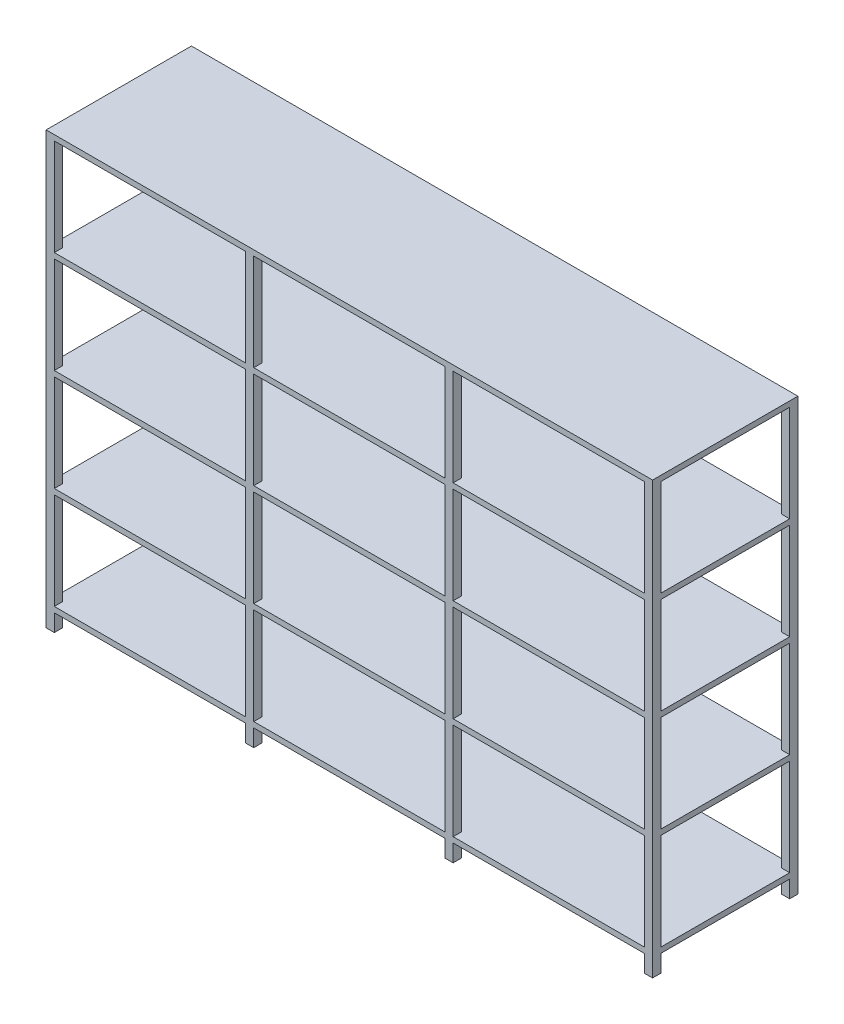
from build123d import *

# Parameters (mm, degrees)
CROQUIS1_W                = 38.1
CROQUIS1_H                = 38.1
SALIENTE_EXTRUIR1_DEPTH   = 80
SALIENTE_EXTRUIR1_2_DEPTH = 80
SALIENTE_EXTRUIR1_3_DEPTH = 80
SALIENTE_EXTRUIR1_4_DEPTH = 80
SALIENTE_EXTRUIR1_5_DEPTH = 80
SALIENTE_EXTRUIR1_6_DEPTH = 80
SALIENTE_EXTRUIR1_7_DEPTH = 80
SALIENTE_EXTRUIR1_8_DEPTH = 80
CROQUIS2_W                = 2822.4
CROQUIS2_H                = 676.2
SALIENTE_EXTRUIR2_DEPTH   = 25.4
CROQUIS3_W                = 38.1
CROQUIS3_H                = 38.1
SALIENTE_EXTRUIR3_DEPTH   = 450
CROQUIS4_W                = 2822.4
CROQUIS4_H                = 676.2
SALIENTE_EXTRUIR4_DEPTH   = 25.4
CROQUIS5_W                = 38.1
CROQUIS5_H                = 38.1
SALIENTE_EXTRUIR5_DEPTH   = 450
CROQUIS6_W                = 2822.4
CROQUIS6_H                = 676.2
SALIENTE_EXTRUIR6_DEPTH   = 25.4
CROQUIS7_W                = 38.1
CROQUIS7_H                = 38.1
SALIENTE_EXTRUIR7_DEPTH   = 450
CROQUIS8_W                = 2822.4
CROQUIS8_H                = 676.2
SALIENTE_EXTRUIR8_DEPTH   = 25.4
CROQUIS9_W                = 38.1
CROQUIS9_H                = 38.1
SALIENTE_EXTRUIR9_DEPTH   = 450
CROQUIS10_W               = 2822.4
CROQUIS10_H               = 676.2
SALIENTE_EXTRUIR10_DEPTH  = 25.4


with BuildPart() as part:
    # Croquis1 → Saliente-Extruir1 (new body)
    with BuildSketch(Plane(origin=(0, 0, 0), x_dir=(1, 0, 0), z_dir=(0, 1, 0))):
        with Locations((19.05, -19.05)):
            Rectangle(CROQUIS1_W, CROQUIS1_H)
    extrude(amount=SALIENTE_EXTRUIR1_DEPTH)



with BuildPart() as body_2:
    # Croquis1 → Saliente-Extruir1 2 (new body)
    with BuildSketch(Plane(origin=(0, 0, 0), x_dir=(1, 0, 0), z_dir=(0, 1, 0))):
        with Locations((947.15, -19.05)):
            Rectangle(CROQUIS1_W, CROQUIS1_H)
    extrude(amount=SALIENTE_EXTRUIR1_2_DEPTH)


with BuildPart() as body_3:
    # Croquis1 → Saliente-Extruir1 3 (new body)
    with BuildSketch(Plane(origin=(0, 0, 0), x_dir=(1, 0, 0), z_dir=(0, 1, 0))):
        with Locations((1875.25, -19.05)):
            Rectangle(CROQUIS1_W, CROQUIS1_H)
    extrude(amount=SALIENTE_EXTRUIR1_3_DEPTH)


with BuildPart() as body_4:
    # Croquis1 → Saliente-Extruir1 4 (new body)
    with BuildSketch(Plane(origin=(0, 0, 0), x_dir=(1, 0, 0), z_dir=(0, 1, 0))):
        with Locations((2803.35, -19.05)):
            Rectangle(CROQUIS1_W, CROQUIS1_H)
    extrude(amount=SALIENTE_EXTRUIR1_4_DEPTH)


with BuildPart() as body_5:
    # Croquis1 → Saliente-Extruir1 5 (new body)
    with BuildSketch(Plane(origin=(0, 0, 0), x_dir=(1, 0, 0), z_dir=(0, 1, 0))):
        with Locations((2803.35, -657.15)):
            Rectangle(CROQUIS1_W, CROQUIS1_H)
    extrude(amount=SALIENTE_EXTRUIR1_5_DEPTH)


with BuildPart() as body_6:
    # Croquis1 → Saliente-Extruir1 6 (new body)
    with BuildSketch(Plane(origin=(0, 0, 0), x_dir=(1, 0, 0), z_dir=(0, 1, 0))):
        with Locations((1875.25, -657.15)):
            Rectangle(CROQUIS1_W, CROQUIS1_H)
    extrude(amount=SALIENTE_EXTRUIR1_6_DEPTH)


with BuildPart() as body_7:
    # Croquis1 → Saliente-Extruir1 7 (new body)
    with BuildSketch(Plane(origin=(0, 0, 0), x_dir=(1, 0, 0), z_dir=(0, 1, 0))):
        with Locations((947.15, -657.15)):
            Rectangle(CROQUIS1_W, CROQUIS1_H)
    extrude(amount=SALIENTE_EXTRUIR1_7_DEPTH)


with BuildPart() as body_8:
    # Croquis1 → Saliente-Extruir1 8 (new body)
    with BuildSketch(Plane(origin=(0, 0, 0), x_dir=(1, 0, 0), z_dir=(0, 1, 0))):
        with Locations((19.05, -657.15)):
            Rectangle(CROQUIS1_W, CROQUIS1_H)
    extrude(amount=SALIENTE_EXTRUIR1_8_DEPTH)


with BuildPart() as part_1:
    add(part.part)

    add(body_2.part)  # Saliente-Extruir2 merges body 2

    add(body_3.part)  # Saliente-Extruir2 merges body 3

    add(body_4.part)  # Saliente-Extruir2 merges body 4

    add(body_5.part)  # Saliente-Extruir2 merges body 5

    add(body_6.part)  # Saliente-Extruir2 merges body 6

    add(body_7.part)  # Saliente-Extruir2 merges body 7

    add(body_8.part)  # Saliente-Extruir2 merges body 8
    # Croquis2 → Saliente-Extruir2 (add)
    with BuildSketch(Plane(origin=(0, 80, 0), x_dir=(1, 0, 0), z_dir=(0, 1, 0))):
        with Locations((1411.2, -338.1)):
            Rectangle(CROQUIS2_W, CROQUIS2_H)
    extrude(amount=SALIENTE_EXTRUIR2_DEPTH)

    # Croquis3 → Saliente-Extruir3 (add)
    with BuildSketch(Plane(origin=(0, 105.4, 0), x_dir=(1, 0, 0), z_dir=(0, 1, 0))):
        with Locations((19.05, -19.05)):
            Rectangle(CROQUIS3_W, CROQUIS3_H)
        with Locations((947.15, -19.05)):
            Rectangle(CROQUIS3_W, CROQUIS3_H)
        with Locations((1875.25, -19.05)):
            Rectangle(CROQUIS3_W, CROQUIS3_H)
        with Locations((2803.35, -19.05)):
            Rectangle(CROQUIS3_W, CROQUIS3_H)
        with Locations((2803.35, -657.15)):
            Rectangle(CROQUIS3_W, CROQUIS3_H)
        with Locations((1875.25, -657.15)):
            Rectangle(CROQUIS3_W, CROQUIS3_H)
        with Locations((947.15, -657.15)):
            Rectangle(CROQUIS3_W, CROQUIS3_H)
        with Locations((19.05, -657.15)):
            Rectangle(CROQUIS3_W, CROQUIS3_H)
    extrude(amount=SALIENTE_EXTRUIR3_DEPTH)

    # Croquis4 → Saliente-Extruir4 (add)
    with BuildSketch(Plane(origin=(0, 555.4, 0), x_dir=(1, 0, 0), z_dir=(0, 1, 0))):
        with Locations((1411.2, -338.1)):
            Rectangle(CROQUIS4_W, CROQUIS4_H)
    extrude(amount=SALIENTE_EXTRUIR4_DEPTH)

    # Croquis5 → Saliente-Extruir5 (add)
    with BuildSketch(Plane(origin=(0, 580.8, 0), x_dir=(1, 0, 0), z_dir=(0, 1, 0))):
        with Locations((19.05, -19.05)):
            Rectangle(CROQUIS5_W, CROQUIS5_H)
        with Locations((947.15, -19.05)):
            Rectangle(CROQUIS5_W, CROQUIS5_H)
        with Locations((1875.25, -19.05)):
            Rectangle(CROQUIS5_W, CROQUIS5_H)
        with Locations((2803.35, -19.05)):
            Rectangle(CROQUIS5_W, CROQUIS5_H)
        with Locations((2803.35, -657.15)):
            Rectangle(CROQUIS5_W, CROQUIS5_H)
        with Locations((1875.25, -657.15)):
            Rectangle(CROQUIS5_W, CROQUIS5_H)
        with Locations((947.15, -657.15)):
            Rectangle(CROQUIS5_W, CROQUIS5_H)
        with Locations((19.05, -657.15)):
            Rectangle(CROQUIS5_W, CROQUIS5_H)
    extrude(amount=SALIENTE_EXTRUIR5_DEPTH)

    # Croquis6 → Saliente-Extruir6 (add)
    with BuildSketch(Plane(origin=(0, 1030.8, 0), x_dir=(1, 0, 0), z_dir=(0, 1, 0))):
        with Locations((1411.2, -338.1)):
            Rectangle(CROQUIS6_W, CROQUIS6_H)
    extrude(amount=SALIENTE_EXTRUIR6_DEPTH)

    # Croquis7 → Saliente-Extruir7 (add)
    with BuildSketch(Plane(origin=(0, 1056.2, 0), x_dir=(1, 0, 0), z_dir=(0, 1, 0))):
        with Locations((19.05, -19.05)):
            Rectangle(CROQUIS7_W, CROQUIS7_H)
        with Locations((947.15, -19.05)):
            Rectangle(CROQUIS7_W, CROQUIS7_H)
        with Locations((1875.25, -19.05)):
            Rectangle(CROQUIS7_W, CROQUIS7_H)
        with Locations((2803.35, -19.05)):
            Rectangle(CROQUIS7_W, CROQUIS7_H)
        with Locations((2803.35, -657.15)):
            Rectangle(CROQUIS7_W, CROQUIS7_H)
        with Locations((1875.25, -657.15)):
            Rectangle(CROQUIS7_W, CROQUIS7_H)
        with Locations((947.15, -657.15)):
            Rectangle(CROQUIS7_W, CROQUIS7_H)
        with Locations((19.05, -657.15)):
            Rectangle(CROQUIS7_W, CROQUIS7_H)
    extrude(amount=SALIENTE_EXTRUIR7_DEPTH)

    # Croquis8 → Saliente-Extruir8 (add)
    with BuildSketch(Plane(origin=(0, 1506.2, 0), x_dir=(1, 0, 0), z_dir=(0, 1, 0))):
        with Locations((1411.2, -338.1)):
            Rectangle(CROQUIS8_W, CROQUIS8_H)
    extrude(amount=SALIENTE_EXTRUIR8_DEPTH)

    # Croquis9 → Saliente-Extruir9 (add)
    with BuildSketch(Plane(origin=(0, 1531.6, 0), x_dir=(1, 0, 0), z_dir=(0, 1, 0))):
        with Locations((19.05, -19.05)):
            Rectangle(CROQUIS9_W, CROQUIS9_H)
        with Locations((947.15, -19.05)):
            Rectangle(CROQUIS9_W, CROQUIS9_H)
        with Locations((1875.25, -19.05)):
            Rectangle(CROQUIS9_W, CROQUIS9_H)
        with Locations((2803.35, -19.05)):
            Rectangle(CROQUIS9_W, CROQUIS9_H)
        with Locations((2803.35, -657.15)):
            Rectangle(CROQUIS9_W, CROQUIS9_H)
        with Locations((1875.25, -657.15)):
            Rectangle(CROQUIS9_W, CROQUIS9_H)
        with Locations((947.15, -657.15)):
            Rectangle(CROQUIS9_W, CROQUIS9_H)
        with Locations((19.05, -657.15)):
            Rectangle(CROQUIS9_W, CROQUIS9_H)
    extrude(amount=SALIENTE_EXTRUIR9_DEPTH)

    # Croquis10 → Saliente-Extruir10 (add)
    with BuildSketch(Plane(origin=(0, 1981.6, 0), x_dir=(1, 0, 0), z_dir=(0, 1, 0))):
        with Locations((1411.2, -338.1)):
            Rectangle(CROQUIS10_W, CROQUIS10_H)
    extrude(amount=SALIENTE_EXTRUIR10_DEPTH)


solid = part_1.part
